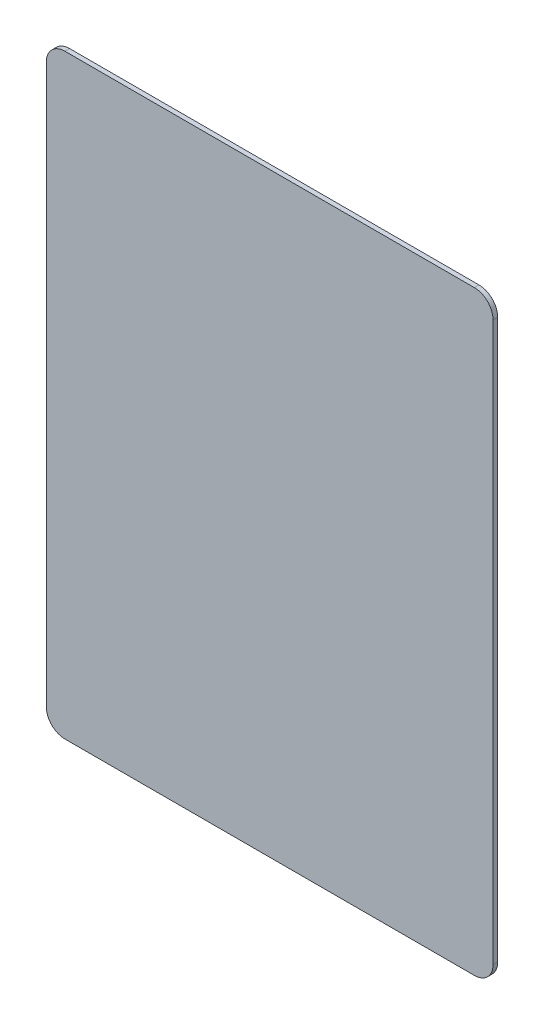
from build123d import *

# Parameters (mm, degrees)
BOSS_EXTRUDE1_DEPTH = 1.5875


with BuildPart() as part:
    # Sketch1 → Boss-Extrude1 (new body)
    with BuildSketch(Plane.XY):
        with BuildLine():
            Line((-47.486956522, 164.133695652), (92.213043478, 164.133695652))
            ThreePointArc((92.213043478, 164.133695652), (96.703171539, 162.273823713), (98.563043478, 157.783695652))
            Line((98.563043478, 157.783695652), (98.563043478, -32.716304348))
            ThreePointArc((98.563043478, -32.716304348), (96.703171539, -37.206432408), (92.213043478, -39.066304348))
            Line((92.213043478, -39.066304348), (-47.486956522, -39.066304348))
            ThreePointArc((-47.486956522, -39.066304348), (-51.977084582, -37.206432408), (-53.836956522, -32.716304348))
            Line((-53.836956522, -32.716304348), (-53.836956522, 157.783695652))
            ThreePointArc((-53.836956522, 157.783695652), (-51.977084582, 162.273823713), (-47.486956522, 164.133695652))
        make_face()
    extrude(amount=BOSS_EXTRUDE1_DEPTH)


solid = part.part
